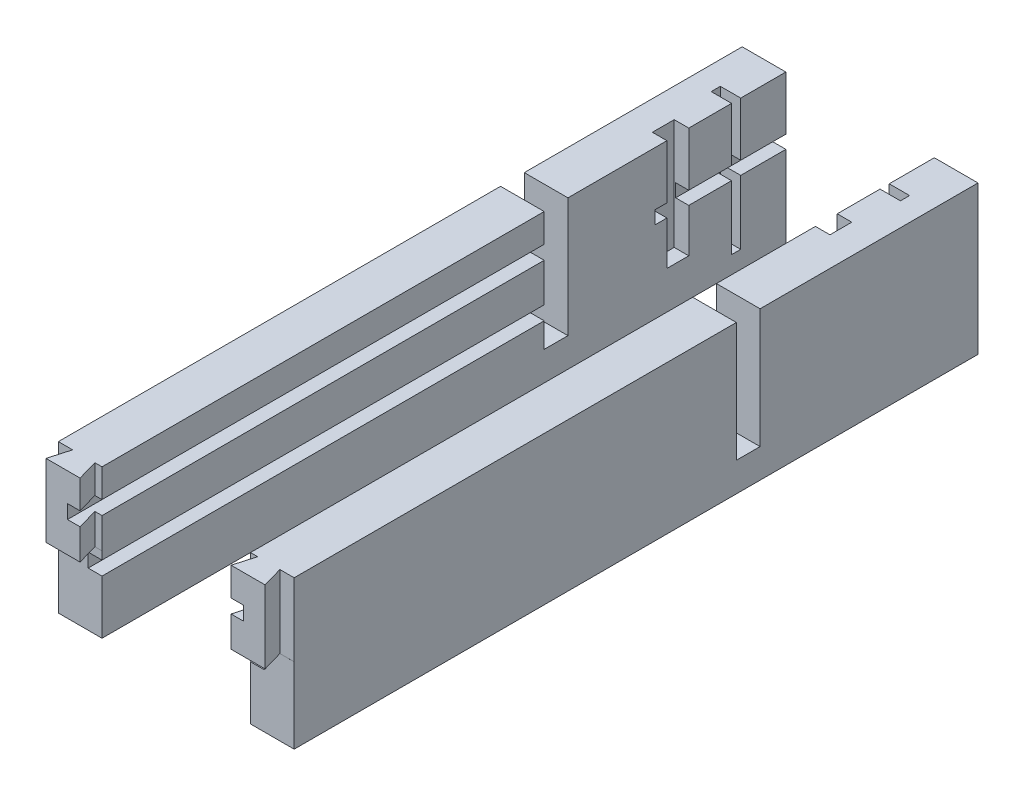
from build123d import *

# Parameters (mm, degrees)
SKETCH1_W           = 242
SKETCH1_H           = 51
BOSS_EXTRUDE1_DEPTH = 15
CUT_EXTRUDE8_DEPTH  = 25
SKETCH13_W          = 15
SKETCH13_H          = 7.11
CUT_EXTRUDE9_DEPTH  = 26
SKETCH17_W          = 15
SKETCH17_H          = 8.15
CUT_EXTRUDE10_DEPTH = 41
SKETCH7_W           = 4.75
SKETCH7_H           = 4.75
CUT_EXTRUDE5_DEPTH  = 165
SKETCH22_W          = 7
SKETCH22_H          = 3.15
CUT_EXTRUDE13_DEPTH = 45
SKETCH18_W          = 5
SKETCH18_H          = 7.5
CUT_EXTRUDE11_DEPTH = 38
SKETCH23_W          = 4.5
SKETCH23_H          = 4.5
CUT_EXTRUDE14_DEPTH = 45


with BuildPart() as part:
    # Sketch1 → Boss-Extrude1 (new body)
    with BuildSketch(Plane(origin=(0, 0, 0), x_dir=(0, 0, -1), z_dir=(1, 0, 0))):
        with Locations((56.437921078, 5.057266603)):
            Rectangle(SKETCH1_W, SKETCH1_H)
    extrude(amount=BOSS_EXTRUDE1_DEPTH)

    # Sketch12 → Cut-Extrude8 (cut)
    with BuildSketch(Plane(origin=(0, 30.557266603, 0), x_dir=(1, 0, 0), z_dir=(0, 1, 0))):
        Polygon((0, -57.448742372), (4.909716433, -57.448742372), (2.87, -64.562078922), (0, -64.562078922), align=None)
        Polygon((15, -57.448742372), (15, -64.562078922), (14.57, -64.562078922), (12.530283567, -57.448742372), align=None)
    extrude(amount=-CUT_EXTRUDE8_DEPTH, mode=Mode.SUBTRACT)

    # Sketch13 → Cut-Extrude9 (cut)
    with BuildSketch(Plane.XZ.offset(20.442733397)):
        with Locations((7.5, 61.007078922)):
            Rectangle(SKETCH13_W, SKETCH13_H)
    extrude(amount=-CUT_EXTRUDE9_DEPTH, mode=Mode.SUBTRACT)

    # Sketch17 → Cut-Extrude10 (cut)
    with BuildSketch(Plane(origin=(0, 30.557266603, 0), x_dir=(1, 0, 0), z_dir=(0, 1, 0))):
        with Locations((7.5, 98.512921078)):
            Rectangle(SKETCH17_W, SKETCH17_H)
    extrude(amount=-CUT_EXTRUDE10_DEPTH, mode=Mode.SUBTRACT)

    # Sketch7 → Cut-Extrude5 (cut)
    with BuildSketch(Plane(origin=(0, 0, -94.437921078), x_dir=(-1, 0, 0), z_dir=(0, 0, -1))):
        with Locations((-12.625, 0.432266603)):
            Rectangle(SKETCH7_W, SKETCH7_H)
        with Locations((-12.625, 18.432266603)):
            Rectangle(SKETCH7_W, SKETCH7_H)
    extrude(amount=-CUT_EXTRUDE5_DEPTH, mode=Mode.SUBTRACT)

    # Sketch22 → Cut-Extrude13 (cut)
    with BuildSketch(Plane(origin=(0, 30.557266603, 0), x_dir=(1, 0, 0), z_dir=(0, 1, 0))):
        with Locations((11.5, 160.362921078)):
            Rectangle(SKETCH22_W, SKETCH22_H)
    extrude(amount=-CUT_EXTRUDE13_DEPTH, mode=Mode.SUBTRACT)

    # Sketch18 → Cut-Extrude11 (cut)
    with BuildSketch(Plane(origin=(0, 30.557266603, 0), x_dir=(1, 0, 0), z_dir=(0, 1, 0))):
        with Locations((12.5, 140.337921078)):
            Rectangle(SKETCH18_W, SKETCH18_H)
    extrude(amount=-CUT_EXTRUDE11_DEPTH, mode=Mode.SUBTRACT)

    # Sketch23 → Cut-Extrude14 (cut)
    with BuildSketch(Plane(origin=(0, 0, -177.437921078), x_dir=(-1, 0, 0), z_dir=(0, 0, -1))):
        with Locations((-12.75, 9.807266603)):
            Rectangle(SKETCH23_W, SKETCH23_H)
    extrude(amount=-CUT_EXTRUDE14_DEPTH, mode=Mode.SUBTRACT)


with BuildPart() as body_2:
    # Mirror4: mirrored copy
    add(part.part.mirror(Plane(origin=(40.5, 0, 0), x_dir=(0, 0, 1), z_dir=(1, 0, 0))))


solid = Compound([part.part, body_2.part])
